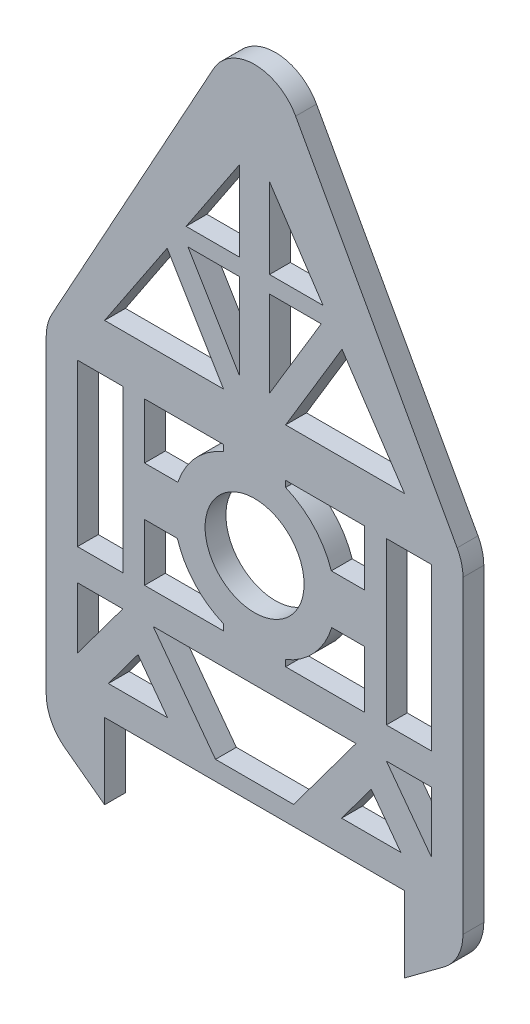
from build123d import *

# Parameters (mm, degrees)
SKETCH1_R           = 47.5
BOSS_EXTRUDE1_DEPTH = 20
FILLET1_R           = 45


with BuildPart() as part:
    # Sketch1 → Boss-Extrude1 (new body)
    with BuildSketch(Plane.XY):
        Polygon((-194.485228659, -273.050238686), (93.403745832, -273.050238686), (93.403745832, -345.680466299), (149.459258586, -304.039615326), (149.459258586, -273.050238686), (149.459258586, 26.949761314), (-50.540741414, 389.92600238), (-250.540741414, 26.949761314), (-250.540741414, -273.050238686), (-250.540741414, -304.039615326), (-194.485228659, -345.680466299), align=None)
        with Locations((-50.540741414, -66.594312027)):
            Circle(SKETCH1_R, mode=Mode.SUBTRACT)
        Polygon((-220.540741414, -174.094312027), (-177.031307775, -174.094312027), (-220.540741414, -232.665247906), align=None, mode=Mode.SUBTRACT)
        Polygon((-88.038179167, -254.669001578), (-147.89310645, -174.094312027), (46.811623623, -174.094312027), (-13.043303661, -254.669001578), align=None, mode=Mode.SUBTRACT)
        Polygon((89.802053233, -243.050238686), (32.959395338, -243.050238686), (61.380724285, -204.790401769), align=None, mode=Mode.SUBTRACT)
        Polygon((-220.540741414, -144.094312027), (-177.031307775, -144.094312027), (-177.031307775, -94.25920837), (-177.031307775, -51.592409031), (-177.031307775, 10.905687973), (-220.540741414, 10.905687973), (-220.540741414, -51.592409031), (-220.540741414, -94.25920837), align=None, mode=Mode.SUBTRACT)
        Polygon((-64.881138394, 251.355896711), (-116.293954083, 174.236673178), (-64.881138394, 174.236673178), align=None, mode=Mode.SUBTRACT)
        Polygon((93.403745832, 56.949761314), (33.381498462, 146.983132367), (-20.768536019, 56.949761314), align=None, mode=Mode.SUBTRACT)
        Polygon((-194.485228659, 56.949761314), (-80.312946809, 56.949761314), (-134.46298129, 146.983132367), align=None, mode=Mode.SUBTRACT)
        Polygon((119.459258586, -232.665247906), (75.949824948, -174.094312027), (119.459258586, -174.094312027), align=None, mode=Mode.SUBTRACT)
        Polygon((119.459258586, -144.094312027), (119.459258586, -94.25920837), (119.459258586, -51.592409031), (119.459258586, 10.905687973), (75.949824948, 10.905687973), (75.949824948, -51.592409031), (75.949824948, -94.25920837), (75.949824948, -144.094312027), align=None, mode=Mode.SUBTRACT)
        Polygon((-190.883536061, -243.050238686), (-134.040878165, -243.050238686), (-162.462207113, -204.790401769), align=None, mode=Mode.SUBTRACT)
        with BuildLine():
            Line((-156.167658148, 10.905687973), (-156.167658148, -42.439597831))
            Line((-156.167658148, -42.439597831), (-124.18040316, -42.439597831))
            ThreePointArc((-124.18040316, -42.439597831), (-107.419195748, -13.953154816), (-80.312946809, 4.958925397))
            Line((-80.312946809, 4.958925397), (-80.312946809, 10.905687973))
            Line((-80.312946809, 10.905687973), (-156.167658148, 10.905687973))
        make_face(mode=Mode.SUBTRACT)
        with BuildLine():
            Line((-156.167658148, -144.094312027), (-156.167658148, -89.328160682))
            Line((-156.167658148, -89.328160682), (-124.631375946, -89.328160682))
            ThreePointArc((-124.631375946, -89.328160682), (-107.922842799, -118.686004653), (-80.312946809, -138.147549452))
            Line((-80.312946809, -138.147549452), (-80.312946809, -144.094312027))
            Line((-80.312946809, -144.094312027), (-156.167658148, -144.094312027))
        make_face(mode=Mode.SUBTRACT)
        with BuildLine():
            Line((-20.768536019, -138.147549452), (-20.768536019, -144.094312027))
            Line((-20.768536019, -144.094312027), (55.08617532, -144.094312027))
            Line((55.08617532, -144.094312027), (55.08617532, -89.328160682))
            Line((55.08617532, -89.328160682), (23.549893118, -89.328160682))
            ThreePointArc((23.549893118, -89.328160682), (6.841359971, -118.686004653), (-20.768536019, -138.147549452))
        make_face(mode=Mode.SUBTRACT)
        with BuildLine():
            Line((-20.768536019, 4.958925397), (-20.768536019, 10.905687973))
            Line((-20.768536019, 10.905687973), (55.08617532, 10.905687973))
            Line((55.08617532, 10.905687973), (55.08617532, -42.439597831))
            Line((55.08617532, -42.439597831), (23.098920333, -42.439597831))
            ThreePointArc((23.098920333, -42.439597831), (6.337712921, -13.953154816), (-20.768536019, 4.958925397))
        make_face(mode=Mode.SUBTRACT)
        Polygon((13.443150149, 158.032314781), (-36.200344433, 158.032314781), (-36.200344433, 75.49181022), align=None, mode=Mode.SUBTRACT)
        Polygon((15.212471256, 174.236673178), (-36.200344433, 251.355896711), (-36.200344433, 174.236673178), align=None, mode=Mode.SUBTRACT)
        Polygon((-114.524632976, 158.032314781), (-64.881138394, 75.49181022), (-64.881138394, 158.032314781), align=None, mode=Mode.SUBTRACT)
    extrude(amount=BOSS_EXTRUDE1_DEPTH)

    # Fillet1
    fillet1_edges = [part.edges().sort_by_distance(p)[0] for p in [
        (149.459258586, -304.039615326, 10),
        (-250.540741414, -304.039615326, 10),
        (-250.540741414, 26.949761314, 10),
        (-50.540741414, 389.92600238, 10),
        (149.459258586, 26.949761314, 10),
    ]]
    fillet(fillet1_edges, radius=FILLET1_R)


solid = part.part
